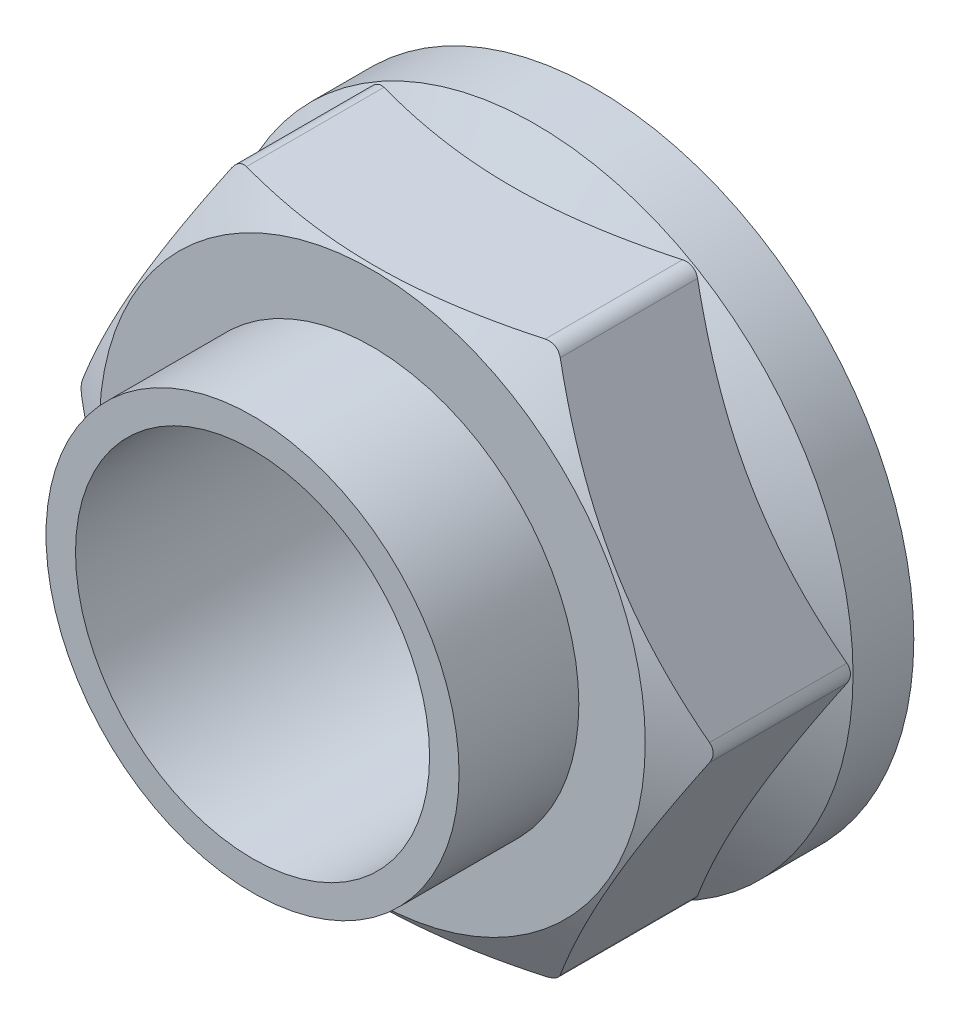
from build123d import *

# Parameters (mm, degrees)
SKETCH2_R           = 10.2
BOSS_EXTRUDE1_DEPTH = 12.9
SKETCH4_R           = 11.9
SKETCH4_R_2         = 10.2
BOSS_EXTRUDE2_DEPTH = 19.8


with BuildPart() as part:
    # Sketch1 → Revolve1 (revolve)
    with BuildSketch(Plane(origin=(0, 0, 0), x_dir=(0, 0, -1), z_dir=(1, 0, 0))):
        Polygon((0, 10.2), (0, 18.3), (-3.5, 18.3), (-8.17653718, 10.2), align=None)
    revolve(axis=Axis((0, 0, 27.758529938), (0, 0, -1)))

    # Sketch2 → Boss-Extrude1 (add)
    with BuildSketch(Plane.XY):
        with BuildLine():
            Line((18.071063426, 0.5), (9.468544415, 15.4))
            ThreePointArc((9.468544415, 15.4), (9.102519011, 15.766025404), (8.602519011, 15.9))
            Line((8.602519011, 15.9), (-8.602519011, 15.9))
            ThreePointArc((-8.602519011, 15.9), (-9.102519011, 15.766025404), (-9.468544415, 15.4))
            Line((-9.468544415, 15.4), (-18.071063426, 0.5))
            ThreePointArc((-18.071063426, 0.5), (-18.205038022, 0), (-18.071063426, -0.5))
            Line((-18.071063426, -0.5), (-9.468544415, -15.4))
            ThreePointArc((-9.468544415, -15.4), (-9.102519011, -15.766025404), (-8.602519011, -15.9))
            Line((-8.602519011, -15.9), (8.602519011, -15.9))
            ThreePointArc((8.602519011, -15.9), (9.102519011, -15.766025404), (9.468544415, -15.4))
            Line((9.468544415, -15.4), (18.071063426, -0.5))
            ThreePointArc((18.071063426, -0.5), (18.205038022, 0), (18.071063426, 0.5))
        make_face()
        Circle(SKETCH2_R, mode=Mode.SUBTRACT)
    extrude(amount=BOSS_EXTRUDE1_DEPTH)

    # Sketch3 → Cut-Revolve2 (revolve, cut)
    with BuildSketch(Plane(origin=(0, 0, 0), x_dir=(0, 0, -1), z_dir=(1, 0, 0))):
        Polygon((-11.414359354, 18.3), (-21.97986928, 0), (-22.588162692, 0), (-22.588162692, 18.3), align=None)
    revolve(axis=Axis((0, 0, 0), (0, 0, 1)), mode=Mode.SUBTRACT)

    # Sketch4 → Boss-Extrude2 (add)
    with BuildSketch(Plane.XY):
        Circle(SKETCH4_R)
        Circle(SKETCH4_R_2, mode=Mode.SUBTRACT)
    extrude(amount=BOSS_EXTRUDE2_DEPTH)


solid = part.part
